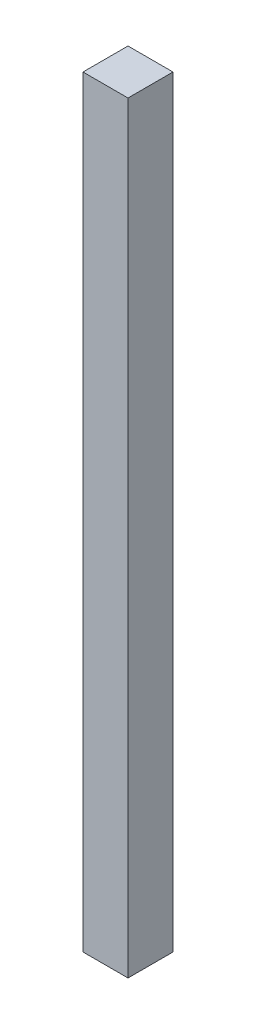
from build123d import *

# Parameters (mm, degrees)
SKETCH1_W           = 25.4
SKETCH1_H           = 25.4
BOSS_EXTRUDE1_DEPTH = 430


with BuildPart() as part:
    # Sketch1 → Boss-Extrude1 (new body)
    with BuildSketch(Plane(origin=(0, 0, 0), x_dir=(1, 0, 0), z_dir=(0, 1, 0))):
        with Locations((-27.135508984, 5.913615805)):
            Rectangle(SKETCH1_W, SKETCH1_H)
    extrude(amount=BOSS_EXTRUDE1_DEPTH)


solid = part.part
